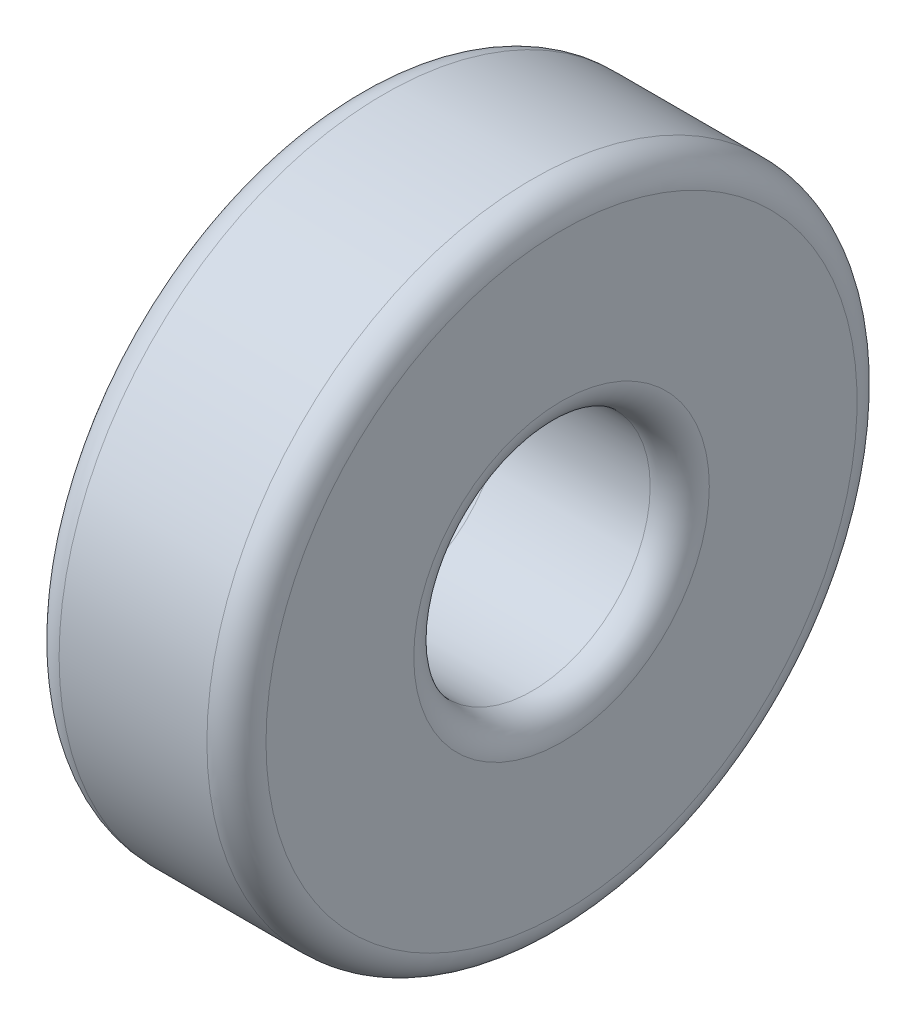
from build123d import *

# Parameters (mm, degrees)
SKETCH1_W = 7
SKETCH1_H = 7
FILLET1_R = 1


with BuildPart() as part:
    # Sketch1 → Revolve1 (revolve)
    with BuildSketch(Plane.XY):
        with Locations((0, 7.5)):
            Rectangle(SKETCH1_W, SKETCH1_H)
    revolve(axis=Axis((0, 0, 0), (1, 0, 0)))

    # Fillet1
    fillet1_edges = [part.edges().sort_by_distance(p)[0] for p in [
        (-3.5, -4, 0),
        (3.5, -4, 0),
        (3.5, -11, 0),
        (-3.5, -11, 0),
    ]]
    fillet(fillet1_edges, radius=FILLET1_R)


solid = part.part
